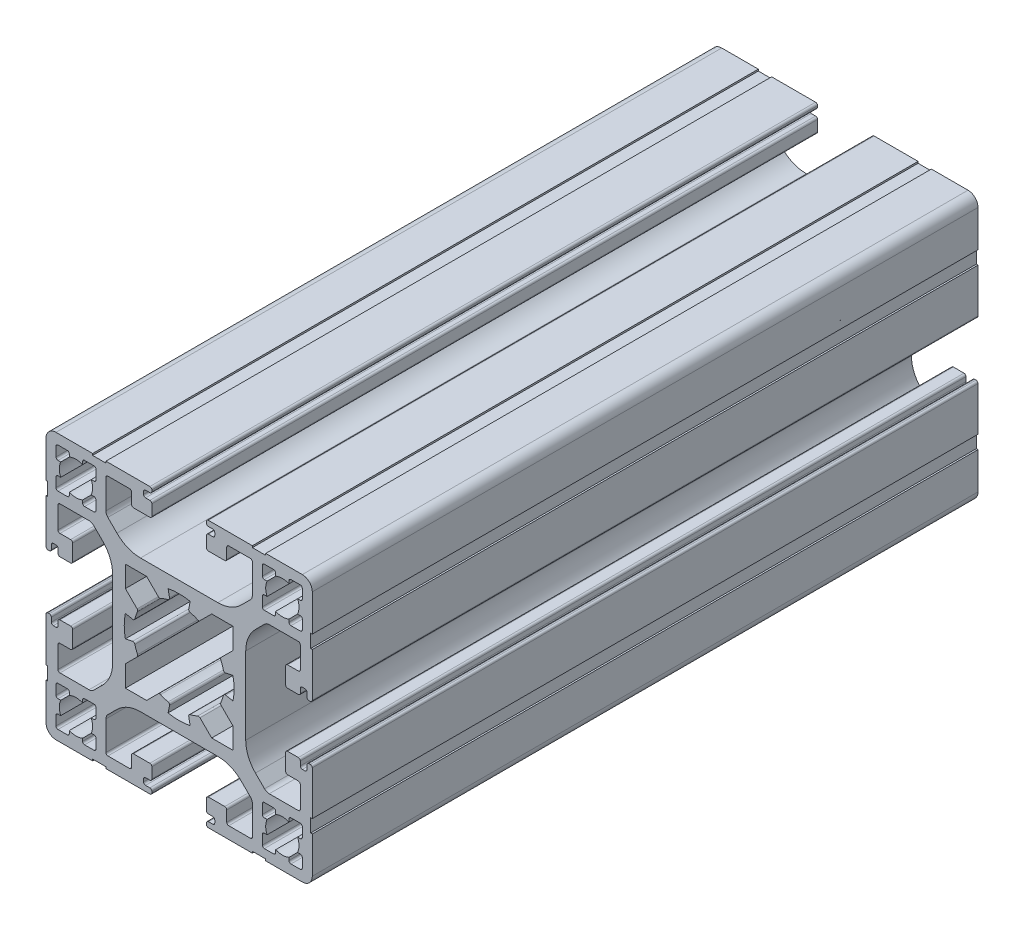
from build123d import *

# Parameters (mm, degrees)
QUADRADO_PF40_01_PERFIL_4040_B_SICO_1_DEPTH = 100


with BuildPart() as part:
    # Sketch1 → Quadrado PF40-01 - PERFIL 4040 BÁSICO(1) (new body)
    with BuildSketch(Plane(origin=(0, 0, 50), x_dir=(0, -1, 0), z_dir=(0, 0, -1))):
        with BuildLine():
            Line((-9.343145751, 11.464466094), (-10.707106781, 12.828427125))
            ThreePointArc((-10.707106781, 12.828427125), (-10.923879533, 13.152850474), (-11, 13.535533906))
            Line((-11, 13.535533906), (-11, 17.9))
            ThreePointArc((-11, 17.9), (-10.912132034, 18.112132034), (-10.7, 18.2))
            Line((-10.7, 18.2), (-7.45, 18.2))
            ThreePointArc((-7.45, 18.2), (-7.237867966, 18.112132034), (-7.15, 17.9))
            Line((-7.15, 17.9), (-7.15, 16.3))
            ThreePointArc((-7.15, 16.3), (-7.062132034, 16.087867966), (-6.85, 16))
            Line((-6.85, 16), (-4.4, 16))
            ThreePointArc((-4.4, 16), (-4.187867966, 16.087867966), (-4.1, 16.3))
            Line((-4.1, 16.3), (-4.1, 17.9))
            ThreePointArc((-4.1, 17.9), (-4.187867966, 18.112132034), (-4.4, 18.2))
            Line((-4.4, 18.2), (-5.05, 18.2))
            ThreePointArc((-5.05, 18.2), (-5.262132034, 18.287867966), (-5.35, 18.5))
            Line((-5.35, 18.5), (-5.35, 18.9))
            ThreePointArc((-5.35, 18.9), (-5.262132034, 19.112132034), (-5.05, 19.2))
            Line((-5.05, 19.2), (-4.4, 19.2))
            ThreePointArc((-4.4, 19.2), (-4.187867966, 19.287867966), (-4.1, 19.5))
            Line((-4.1, 19.5), (-4.1, 19.699999929))
            ThreePointArc((-4.1, 19.699999929), (-4.187867966, 19.912131964), (-4.4, 19.999999929))
            Line((-4.4, 19.999999929), (-10.999999929, 19.999999929))
            Line((-10.999999929, 19.999999929), (-10.999999929, 19.749999873))
            Line((-10.999999929, 19.749999873), (-12.999999929, 19.749999873))
            Line((-12.999999929, 19.749999873), (-12.999999929, 19.999999929))
            Line((-12.999999929, 19.999999929), (-18.499999873, 19.999999929))
            ThreePointArc((-18.499999873, 19.999999929), (-19.560660045, 19.560660101), (-19.999999873, 18.499999929))
            Line((-19.999999873, 18.499999929), (-19.999999873, 12.999999929))
            Line((-19.999999873, 12.999999929), (-19.749999873, 12.999999929))
            Line((-19.749999873, 12.999999929), (-19.749999873, 10.999999929))
            Line((-19.749999873, 10.999999929), (-19.999999929, 10.999999929))
            Line((-19.999999929, 10.999999929), (-19.999999929, 4.4))
            ThreePointArc((-19.999999929, 4.4), (-19.912131964, 4.187867966), (-19.699999929, 4.1))
            Line((-19.699999929, 4.1), (-19.5, 4.1))
            ThreePointArc((-19.5, 4.1), (-19.287867966, 4.187867966), (-19.2, 4.4))
            Line((-19.2, 4.4), (-19.2, 5.05))
            ThreePointArc((-19.2, 5.05), (-19.112132034, 5.262132034), (-18.9, 5.35))
            Line((-18.9, 5.35), (-18.5, 5.35))
            ThreePointArc((-18.5, 5.35), (-18.287867966, 5.262132034), (-18.2, 5.05))
            Line((-18.2, 5.05), (-18.2, 4.4))
            ThreePointArc((-18.2, 4.4), (-18.112132034, 4.187867966), (-17.9, 4.1))
            Line((-17.9, 4.1), (-16.3, 4.1))
            ThreePointArc((-16.3, 4.1), (-16.087867966, 4.187867966), (-16, 4.4))
            Line((-16, 4.4), (-16, 6.85))
            ThreePointArc((-16, 6.85), (-16.087867966, 7.062132034), (-16.3, 7.15))
            Line((-16.3, 7.15), (-17.9, 7.15))
            ThreePointArc((-17.9, 7.15), (-18.112132034, 7.237867966), (-18.2, 7.45))
            Line((-18.2, 7.45), (-18.2, 10.7))
            ThreePointArc((-18.2, 10.7), (-18.112132034, 10.912132034), (-17.9, 11))
            Line((-17.9, 11), (-13.535533906, 11))
            ThreePointArc((-13.535533906, 11), (-13.152850474, 10.923879533), (-12.828427125, 10.707106781))
            Line((-12.828427125, 10.707106781), (-11.464466094, 9.343145751))
            ThreePointArc((-11.464466094, 9.343145751), (-10.380602337, 7.721029006), (-10, 5.807611845))
            Line((-10, 5.807611845), (-10, -5.807611845))
            ThreePointArc((-10, -5.807611845), (-10.380602337, -7.721029006), (-11.464466094, -9.343145751))
            Line((-11.464466094, -9.343145751), (-12.828427125, -10.707106781))
            ThreePointArc((-12.828427125, -10.707106781), (-13.152850474, -10.923879533), (-13.535533906, -11))
            Line((-13.535533906, -11), (-17.9, -11))
            ThreePointArc((-17.9, -11), (-18.112132034, -10.912132034), (-18.2, -10.7))
            Line((-18.2, -10.7), (-18.2, -7.45))
            ThreePointArc((-18.2, -7.45), (-18.112132034, -7.237867966), (-17.9, -7.15))
            Line((-17.9, -7.15), (-16.3, -7.15))
            ThreePointArc((-16.3, -7.15), (-16.087867966, -7.062132034), (-16, -6.85))
            Line((-16, -6.85), (-16, -4.4))
            ThreePointArc((-16, -4.4), (-16.087867966, -4.187867966), (-16.3, -4.1))
            Line((-16.3, -4.1), (-17.9, -4.1))
            ThreePointArc((-17.9, -4.1), (-18.112132034, -4.187867966), (-18.2, -4.4))
            Line((-18.2, -4.4), (-18.2, -5.05))
            ThreePointArc((-18.2, -5.05), (-18.287867966, -5.262132034), (-18.5, -5.35))
            Line((-18.5, -5.35), (-18.9, -5.35))
            ThreePointArc((-18.9, -5.35), (-19.112132034, -5.262132034), (-19.2, -5.05))
            Line((-19.2, -5.05), (-19.2, -4.4))
            ThreePointArc((-19.2, -4.4), (-19.287867966, -4.187867966), (-19.5, -4.1))
            Line((-19.5, -4.1), (-19.699999929, -4.1))
            ThreePointArc((-19.699999929, -4.1), (-19.912131964, -4.187867966), (-19.999999929, -4.4))
            Line((-19.999999929, -4.4), (-19.999999929, -10.999999929))
            Line((-19.999999929, -10.999999929), (-19.749999873, -10.999999929))
            Line((-19.749999873, -10.999999929), (-19.749999873, -12.999999929))
            Line((-19.749999873, -12.999999929), (-19.999999873, -12.999999929))
            Line((-19.999999873, -12.999999929), (-19.999999873, -18.499999929))
            ThreePointArc((-19.999999873, -18.499999929), (-19.560660045, -19.560660101), (-18.499999873, -19.999999929))
            Line((-18.499999873, -19.999999929), (-12.999999929, -19.999999929))
            Line((-12.999999929, -19.999999929), (-12.999999929, -19.749999873))
            Line((-12.999999929, -19.749999873), (-10.999999929, -19.749999873))
            Line((-10.999999929, -19.749999873), (-10.999999929, -19.999999929))
            Line((-10.999999929, -19.999999929), (-4.4, -19.999999929))
            ThreePointArc((-4.4, -19.999999929), (-4.187867966, -19.912131964), (-4.1, -19.699999929))
            Line((-4.1, -19.699999929), (-4.1, -19.5))
            ThreePointArc((-4.1, -19.5), (-4.187867966, -19.287867966), (-4.4, -19.2))
            Line((-4.4, -19.2), (-5.05, -19.2))
            ThreePointArc((-5.05, -19.2), (-5.262132034, -19.112132034), (-5.35, -18.9))
            Line((-5.35, -18.9), (-5.35, -18.5))
            ThreePointArc((-5.35, -18.5), (-5.262132034, -18.287867966), (-5.05, -18.2))
            Line((-5.05, -18.2), (-4.4, -18.2))
            ThreePointArc((-4.4, -18.2), (-4.187867966, -18.112132034), (-4.1, -17.9))
            Line((-4.1, -17.9), (-4.1, -16.3))
            ThreePointArc((-4.1, -16.3), (-4.187867966, -16.087867966), (-4.4, -16))
            Line((-4.4, -16), (-6.85, -16))
            ThreePointArc((-6.85, -16), (-7.062132034, -16.087867966), (-7.15, -16.3))
            Line((-7.15, -16.3), (-7.15, -17.9))
            ThreePointArc((-7.15, -17.9), (-7.237867966, -18.112132034), (-7.45, -18.2))
            Line((-7.45, -18.2), (-10.7, -18.2))
            ThreePointArc((-10.7, -18.2), (-10.912132034, -18.112132034), (-11, -17.9))
            Line((-11, -17.9), (-11, -13.535533906))
            ThreePointArc((-11, -13.535533906), (-10.923879533, -13.152850474), (-10.707106781, -12.828427125))
            Line((-10.707106781, -12.828427125), (-9.343145751, -11.464466094))
            ThreePointArc((-9.343145751, -11.464466094), (-7.721029006, -10.380602337), (-5.807611845, -10))
            Line((-5.807611845, -10), (5.807611845, -10))
            ThreePointArc((5.807611845, -10), (7.721029006, -10.380602337), (9.343145751, -11.464466094))
            Line((9.343145751, -11.464466094), (10.707106781, -12.828427125))
            ThreePointArc((10.707106781, -12.828427125), (10.923879533, -13.152850474), (11, -13.535533906))
            Line((11, -13.535533906), (11, -17.9))
            ThreePointArc((11, -17.9), (10.912132034, -18.112132034), (10.7, -18.2))
            Line((10.7, -18.2), (7.45, -18.2))
            ThreePointArc((7.45, -18.2), (7.237867966, -18.112132034), (7.15, -17.9))
            Line((7.15, -17.9), (7.15, -16.3))
            ThreePointArc((7.15, -16.3), (7.062132034, -16.087867966), (6.85, -16))
            Line((6.85, -16), (4.4, -16))
            ThreePointArc((4.4, -16), (4.187867966, -16.087867966), (4.1, -16.3))
            Line((4.1, -16.3), (4.1, -17.9))
            ThreePointArc((4.1, -17.9), (4.187867966, -18.112132034), (4.4, -18.2))
            Line((4.4, -18.2), (5.05, -18.2))
            ThreePointArc((5.05, -18.2), (5.262132034, -18.287867966), (5.35, -18.5))
            Line((5.35, -18.5), (5.35, -18.9))
            ThreePointArc((5.35, -18.9), (5.262132034, -19.112132034), (5.05, -19.2))
            Line((5.05, -19.2), (4.4, -19.2))
            ThreePointArc((4.4, -19.2), (4.187867966, -19.287867966), (4.1, -19.5))
            Line((4.1, -19.5), (4.1, -19.699999929))
            ThreePointArc((4.1, -19.699999929), (4.187867966, -19.912131964), (4.4, -19.999999929))
            Line((4.4, -19.999999929), (10.999999929, -19.999999929))
            Line((10.999999929, -19.999999929), (10.999999929, -19.749999873))
            Line((10.999999929, -19.749999873), (12.999999929, -19.749999873))
            Line((12.999999929, -19.749999873), (12.999999929, -19.999999929))
            Line((12.999999929, -19.999999929), (18.499999873, -19.999999929))
            ThreePointArc((18.499999873, -19.999999929), (19.560660045, -19.560660101), (19.999999873, -18.499999929))
            Line((19.999999873, -18.499999929), (19.999999873, -12.999999929))
            Line((19.999999873, -12.999999929), (19.749999873, -12.999999929))
            Line((19.749999873, -12.999999929), (19.749999873, -10.999999929))
            Line((19.749999873, -10.999999929), (19.999999929, -10.999999929))
            Line((19.999999929, -10.999999929), (19.999999929, -4.4))
            ThreePointArc((19.999999929, -4.4), (19.912131964, -4.187867966), (19.699999929, -4.1))
            Line((19.699999929, -4.1), (19.5, -4.1))
            ThreePointArc((19.5, -4.1), (19.287867966, -4.187867966), (19.2, -4.4))
            Line((19.2, -4.4), (19.2, -5.05))
            ThreePointArc((19.2, -5.05), (19.112132034, -5.262132034), (18.9, -5.35))
            Line((18.9, -5.35), (18.5, -5.35))
            ThreePointArc((18.5, -5.35), (18.287867966, -5.262132034), (18.2, -5.05))
            Line((18.2, -5.05), (18.2, -4.4))
            ThreePointArc((18.2, -4.4), (18.112132034, -4.187867966), (17.9, -4.1))
            Line((17.9, -4.1), (16.3, -4.1))
            ThreePointArc((16.3, -4.1), (16.087867966, -4.187867966), (16, -4.4))
            Line((16, -4.4), (16, -6.85))
            ThreePointArc((16, -6.85), (16.087867966, -7.062132034), (16.3, -7.15))
            Line((16.3, -7.15), (17.9, -7.15))
            ThreePointArc((17.9, -7.15), (18.112132034, -7.237867966), (18.2, -7.45))
            Line((18.2, -7.45), (18.2, -10.7))
            ThreePointArc((18.2, -10.7), (18.112132034, -10.912132034), (17.9, -11))
            Line((17.9, -11), (13.535533906, -11))
            ThreePointArc((13.535533906, -11), (13.152850474, -10.923879533), (12.828427125, -10.707106781))
            Line((12.828427125, -10.707106781), (11.464466094, -9.343145751))
            ThreePointArc((11.464466094, -9.343145751), (10.380602337, -7.721029006), (10, -5.807611845))
            Line((10, -5.807611845), (10, 5.807611845))
            ThreePointArc((10, 5.807611845), (10.380602337, 7.721029006), (11.464466094, 9.343145751))
            Line((11.464466094, 9.343145751), (12.828427125, 10.707106781))
            ThreePointArc((12.828427125, 10.707106781), (13.152850474, 10.923879533), (13.535533906, 11))
            Line((13.535533906, 11), (17.9, 11))
            ThreePointArc((17.9, 11), (18.112132034, 10.912132034), (18.2, 10.7))
            Line((18.2, 10.7), (18.2, 7.45))
            ThreePointArc((18.2, 7.45), (18.112132034, 7.237867966), (17.9, 7.15))
            Line((17.9, 7.15), (16.3, 7.15))
            ThreePointArc((16.3, 7.15), (16.087867966, 7.062132034), (16, 6.85))
            Line((16, 6.85), (16, 4.4))
            ThreePointArc((16, 4.4), (16.087867966, 4.187867966), (16.3, 4.1))
            Line((16.3, 4.1), (17.9, 4.1))
            ThreePointArc((17.9, 4.1), (18.112132034, 4.187867966), (18.2, 4.4))
            Line((18.2, 4.4), (18.2, 5.05))
            ThreePointArc((18.2, 5.05), (18.287867966, 5.262132034), (18.5, 5.35))
            Line((18.5, 5.35), (18.9, 5.35))
            ThreePointArc((18.9, 5.35), (19.112132034, 5.262132034), (19.2, 5.05))
            Line((19.2, 5.05), (19.2, 4.4))
            ThreePointArc((19.2, 4.4), (19.287867966, 4.187867966), (19.5, 4.1))
            Line((19.5, 4.1), (19.699999929, 4.1))
            ThreePointArc((19.699999929, 4.1), (19.912131964, 4.187867966), (19.999999929, 4.4))
            Line((19.999999929, 4.4), (19.999999929, 10.999999929))
            Line((19.999999929, 10.999999929), (19.749999873, 10.999999929))
            Line((19.749999873, 10.999999929), (19.749999873, 12.999999929))
            Line((19.749999873, 12.999999929), (19.999999873, 12.999999929))
            Line((19.999999873, 12.999999929), (19.999999873, 18.499999929))
            ThreePointArc((19.999999873, 18.499999929), (19.560660045, 19.560660101), (18.499999873, 19.999999929))
            Line((18.499999873, 19.999999929), (12.999999929, 19.999999929))
            Line((12.999999929, 19.999999929), (12.999999929, 19.749999873))
            Line((12.999999929, 19.749999873), (10.999999929, 19.749999873))
            Line((10.999999929, 19.749999873), (10.999999929, 19.999999929))
            Line((10.999999929, 19.999999929), (4.4, 19.999999929))
            ThreePointArc((4.4, 19.999999929), (4.187867966, 19.912131964), (4.1, 19.699999929))
            Line((4.1, 19.699999929), (4.1, 19.5))
            ThreePointArc((4.1, 19.5), (4.187867966, 19.287867966), (4.4, 19.2))
            Line((4.4, 19.2), (5.05, 19.2))
            ThreePointArc((5.05, 19.2), (5.262132034, 19.112132034), (5.35, 18.9))
            Line((5.35, 18.9), (5.35, 18.5))
            ThreePointArc((5.35, 18.5), (5.262132034, 18.287867966), (5.05, 18.2))
            Line((5.05, 18.2), (4.4, 18.2))
            ThreePointArc((4.4, 18.2), (4.187867966, 18.112132034), (4.1, 17.9))
            Line((4.1, 17.9), (4.1, 16.3))
            ThreePointArc((4.1, 16.3), (4.187867966, 16.087867966), (4.4, 16))
            Line((4.4, 16), (6.85, 16))
            ThreePointArc((6.85, 16), (7.062132034, 16.087867966), (7.15, 16.3))
            Line((7.15, 16.3), (7.15, 17.9))
            ThreePointArc((7.15, 17.9), (7.237867966, 18.112132034), (7.45, 18.2))
            Line((7.45, 18.2), (10.7, 18.2))
            ThreePointArc((10.7, 18.2), (10.912132034, 18.112132034), (11, 17.9))
            Line((11, 17.9), (11, 13.535533906))
            ThreePointArc((11, 13.535533906), (10.923879533, 13.152850474), (10.707106781, 12.828427125))
            Line((10.707106781, 12.828427125), (9.343145751, 11.464466094))
            ThreePointArc((9.343145751, 11.464466094), (7.721029006, 10.380602337), (5.807611845, 10))
            Line((5.807611845, 10), (-5.807611845, 10))
            ThreePointArc((-5.807611845, 10), (-7.721029006, 10.380602337), (-9.343145751, 11.464466094))
        make_face()
        with BuildLine():
            Line((18.199999873, -16.499999929), (17.791287052, -16.499999929))
            ThreePointArc((17.791287052, -16.499999929), (17.999998571, -15.500001379), (17.791287052, -14.500002829))
            Line((17.791287052, -14.500002829), (18.199999873, -14.500002829))
            ThreePointArc((18.199999873, -14.500002829), (18.412131908, -14.412134864), (18.499999873, -14.200002829))
            Line((18.499999873, -14.200002829), (18.499999873, -12.800002829))
            ThreePointArc((18.499999873, -12.800002829), (18.412131908, -12.587870795), (18.199999873, -12.500002829))
            Line((18.199999873, -12.500002829), (16.799999873, -12.500002829))
            ThreePointArc((16.799999873, -12.500002829), (16.587867839, -12.587870795), (16.499999873, -12.800002829))
            Line((16.499999873, -12.800002829), (16.499999873, -13.2087141))
            ThreePointArc((16.499999873, -13.2087141), (15.499998571, -13.000001379), (14.49999727, -13.2087141))
            Line((14.49999727, -13.2087141), (14.49999727, -12.800002829))
            ThreePointArc((14.49999727, -12.800002829), (14.412129304, -12.587870795), (14.19999727, -12.500002829))
            Line((14.19999727, -12.500002829), (12.79999727, -12.500002829))
            ThreePointArc((12.79999727, -12.500002829), (12.587865235, -12.587870795), (12.49999727, -12.800002829))
            Line((12.49999727, -12.800002829), (12.49999727, -14.200002829))
            ThreePointArc((12.49999727, -14.200002829), (12.587865235, -14.412134864), (12.79999727, -14.500002829))
            Line((12.79999727, -14.500002829), (13.208710091, -14.500002829))
            ThreePointArc((13.208710091, -14.500002829), (12.999998571, -15.500001379), (13.208710091, -16.499999929))
            Line((13.208710091, -16.499999929), (12.79999727, -16.499999929))
            ThreePointArc((12.79999727, -16.499999929), (12.587865235, -16.587867895), (12.49999727, -16.799999929))
            Line((12.49999727, -16.799999929), (12.49999727, -18.199999929))
            ThreePointArc((12.49999727, -18.199999929), (12.587865235, -18.412131964), (12.79999727, -18.499999929))
            Line((12.79999727, -18.499999929), (14.19999727, -18.499999929))
            ThreePointArc((14.19999727, -18.499999929), (14.412129304, -18.412131964), (14.49999727, -18.199999929))
            Line((14.49999727, -18.199999929), (14.49999727, -17.791288659))
            ThreePointArc((14.49999727, -17.791288659), (15.499998571, -18.000001379), (16.499999873, -17.791288659))
            Line((16.499999873, -17.791288659), (16.499999873, -18.199999929))
            ThreePointArc((16.499999873, -18.199999929), (16.587867839, -18.412131964), (16.799999873, -18.499999929))
            Line((16.799999873, -18.499999929), (18.199999873, -18.499999929))
            ThreePointArc((18.199999873, -18.499999929), (18.412131908, -18.412131964), (18.499999873, -18.199999929))
            Line((18.499999873, -18.199999929), (18.499999873, -16.799999929))
            ThreePointArc((18.499999873, -16.799999929), (18.412131908, -16.587867895), (18.199999873, -16.499999929))
        make_face(mode=Mode.SUBTRACT)
        with BuildLine():
            Line((-6.997249465, 1.439096912), (-8.080865606, 1.661960003))
            ThreePointArc((-8.080865606, 1.661960003), (-8.25, 0), (-8.080865606, -1.661960003))
            Line((-8.080865606, -1.661960003), (-6.997249465, -1.439096912))
            ThreePointArc((-6.997249465, -1.439096912), (-6.777058504, -1.479021377), (-6.6457594, -1.660235526))
            ThreePointArc((-6.6457594, -1.660235526), (-6.474223632, -2.23761667), (-6.252630722, -2.797697099))
            ThreePointArc((-6.252630722, -2.797697099), (-6.231441739, -2.974622257), (-6.314336529, -3.132356014))
            Line((-6.314336529, -3.132356014), (-8.071067812, -4.889087297))
            Line((-8.071067812, -4.889087297), (-8.071067812, -8.071067812))
            Line((-8.071067812, -8.071067812), (-4.889087297, -8.071067812))
            Line((-4.889087297, -8.071067812), (-3.132356014, -6.314336529))
            ThreePointArc((-3.132356014, -6.314336529), (-2.974622257, -6.231441739), (-2.797697099, -6.252630722))
            ThreePointArc((-2.797697099, -6.252630722), (-2.23761667, -6.474223632), (-1.660235526, -6.6457594))
            ThreePointArc((-1.660235526, -6.6457594), (-1.479021377, -6.777058504), (-1.439096912, -6.997249465))
            Line((-1.439096912, -6.997249465), (-1.661960003, -8.080865606))
            ThreePointArc((-1.661960003, -8.080865606), (0, -8.25), (1.661960003, -8.080865606))
            Line((1.661960003, -8.080865606), (1.439096912, -6.997249465))
            ThreePointArc((1.439096912, -6.997249465), (1.479021377, -6.777058504), (1.660235526, -6.6457594))
            ThreePointArc((1.660235526, -6.6457594), (2.23761667, -6.474223632), (2.797697099, -6.252630722))
            ThreePointArc((2.797697099, -6.252630722), (2.974622257, -6.231441739), (3.132356014, -6.314336529))
            Line((3.132356014, -6.314336529), (4.889087297, -8.071067812))
            Line((4.889087297, -8.071067812), (8.071067812, -8.071067812))
            Line((8.071067812, -8.071067812), (8.071067812, -4.889087297))
            Line((8.071067812, -4.889087297), (6.314336529, -3.132356014))
            ThreePointArc((6.314336529, -3.132356014), (6.231441739, -2.974622257), (6.252630722, -2.797697099))
            ThreePointArc((6.252630722, -2.797697099), (6.474223632, -2.23761667), (6.6457594, -1.660235526))
            ThreePointArc((6.6457594, -1.660235526), (6.777058504, -1.479021377), (6.997249465, -1.439096912))
            Line((6.997249465, -1.439096912), (8.080865606, -1.661960003))
            ThreePointArc((8.080865606, -1.661960003), (8.25, 0), (8.080865606, 1.661960003))
            Line((8.080865606, 1.661960003), (6.997249465, 1.439096912))
            ThreePointArc((6.997249465, 1.439096912), (6.777058504, 1.479021377), (6.6457594, 1.660235526))
            ThreePointArc((6.6457594, 1.660235526), (6.474223632, 2.23761667), (6.252630722, 2.797697099))
            ThreePointArc((6.252630722, 2.797697099), (6.231441739, 2.974622257), (6.314336529, 3.132356014))
            Line((6.314336529, 3.132356014), (8.071067812, 4.889087297))
            Line((8.071067812, 4.889087297), (8.071067812, 8.071067812))
            Line((8.071067812, 8.071067812), (4.889087297, 8.071067812))
            Line((4.889087297, 8.071067812), (3.132356014, 6.314336529))
            ThreePointArc((3.132356014, 6.314336529), (2.974622257, 6.231441739), (2.797697099, 6.252630722))
            ThreePointArc((2.797697099, 6.252630722), (2.23761667, 6.474223632), (1.660235526, 6.6457594))
            ThreePointArc((1.660235526, 6.6457594), (1.479021377, 6.777058504), (1.439096912, 6.997249465))
            Line((1.439096912, 6.997249465), (1.661960003, 8.080865606))
            ThreePointArc((1.661960003, 8.080865606), (0, 8.25), (-1.661960003, 8.080865606))
            Line((-1.661960003, 8.080865606), (-1.439096912, 6.997249465))
            ThreePointArc((-1.439096912, 6.997249465), (-1.479021377, 6.777058504), (-1.660235526, 6.6457594))
            ThreePointArc((-1.660235526, 6.6457594), (-2.23761667, 6.474223632), (-2.797697099, 6.252630722))
            ThreePointArc((-2.797697099, 6.252630722), (-2.974622257, 6.231441739), (-3.132356014, 6.314336529))
            Line((-3.132356014, 6.314336529), (-4.889087297, 8.071067812))
            Line((-4.889087297, 8.071067812), (-8.071067812, 8.071067812))
            Line((-8.071067812, 8.071067812), (-8.071067812, 4.889087297))
            Line((-8.071067812, 4.889087297), (-6.314336529, 3.132356014))
            ThreePointArc((-6.314336529, 3.132356014), (-6.231441739, 2.974622257), (-6.252630722, 2.797697099))
            ThreePointArc((-6.252630722, 2.797697099), (-6.474223632, 2.23761667), (-6.6457594, 1.660235526))
            ThreePointArc((-6.6457594, 1.660235526), (-6.777058504, 1.479021377), (-6.997249465, 1.439096912))
        make_face(mode=Mode.SUBTRACT)
        with BuildLine():
            Line((-16.499999873, 17.791288659), (-16.499999873, 18.199999929))
            ThreePointArc((-16.499999873, 18.199999929), (-16.587867839, 18.412131964), (-16.799999873, 18.499999929))
            Line((-16.799999873, 18.499999929), (-18.199999873, 18.499999929))
            ThreePointArc((-18.199999873, 18.499999929), (-18.412131908, 18.412131964), (-18.499999873, 18.199999929))
            Line((-18.499999873, 18.199999929), (-18.499999873, 16.799999929))
            ThreePointArc((-18.499999873, 16.799999929), (-18.412131908, 16.587867895), (-18.199999873, 16.499999929))
            Line((-18.199999873, 16.499999929), (-17.791287052, 16.499999929))
            ThreePointArc((-17.791287052, 16.499999929), (-17.999998571, 15.500001379), (-17.791287052, 14.500002829))
            Line((-17.791287052, 14.500002829), (-18.199999873, 14.500002829))
            ThreePointArc((-18.199999873, 14.500002829), (-18.412131908, 14.412134864), (-18.499999873, 14.200002829))
            Line((-18.499999873, 14.200002829), (-18.499999873, 12.800002829))
            ThreePointArc((-18.499999873, 12.800002829), (-18.412131908, 12.587870795), (-18.199999873, 12.500002829))
            Line((-18.199999873, 12.500002829), (-16.799999873, 12.500002829))
            ThreePointArc((-16.799999873, 12.500002829), (-16.587867839, 12.587870795), (-16.499999873, 12.800002829))
            Line((-16.499999873, 12.800002829), (-16.499999873, 13.2087141))
            ThreePointArc((-16.499999873, 13.2087141), (-15.499998571, 13.000001379), (-14.49999727, 13.2087141))
            Line((-14.49999727, 13.2087141), (-14.49999727, 12.800002829))
            ThreePointArc((-14.49999727, 12.800002829), (-14.412129304, 12.587870795), (-14.19999727, 12.500002829))
            Line((-14.19999727, 12.500002829), (-12.79999727, 12.500002829))
            ThreePointArc((-12.79999727, 12.500002829), (-12.587865235, 12.587870795), (-12.49999727, 12.800002829))
            Line((-12.49999727, 12.800002829), (-12.49999727, 14.200002829))
            ThreePointArc((-12.49999727, 14.200002829), (-12.587865235, 14.412134864), (-12.79999727, 14.500002829))
            Line((-12.79999727, 14.500002829), (-13.208710091, 14.500002829))
            ThreePointArc((-13.208710091, 14.500002829), (-12.999998571, 15.500001379), (-13.208710091, 16.499999929))
            Line((-13.208710091, 16.499999929), (-12.79999727, 16.499999929))
            ThreePointArc((-12.79999727, 16.499999929), (-12.587865235, 16.587867895), (-12.49999727, 16.799999929))
            Line((-12.49999727, 16.799999929), (-12.49999727, 18.199999929))
            ThreePointArc((-12.49999727, 18.199999929), (-12.587865235, 18.412131964), (-12.79999727, 18.499999929))
            Line((-12.79999727, 18.499999929), (-14.19999727, 18.499999929))
            ThreePointArc((-14.19999727, 18.499999929), (-14.412129304, 18.412131964), (-14.49999727, 18.199999929))
            Line((-14.49999727, 18.199999929), (-14.49999727, 17.791288659))
            ThreePointArc((-14.49999727, 17.791288659), (-15.499998571, 18.000001379), (-16.499999873, 17.791288659))
        make_face(mode=Mode.SUBTRACT)
        with BuildLine():
            Line((14.49999727, 17.791288659), (14.49999727, 18.199999929))
            ThreePointArc((14.49999727, 18.199999929), (14.412129304, 18.412131964), (14.19999727, 18.499999929))
            Line((14.19999727, 18.499999929), (12.79999727, 18.499999929))
            ThreePointArc((12.79999727, 18.499999929), (12.587865235, 18.412131964), (12.49999727, 18.199999929))
            Line((12.49999727, 18.199999929), (12.49999727, 16.799999929))
            ThreePointArc((12.49999727, 16.799999929), (12.587865235, 16.587867895), (12.79999727, 16.499999929))
            Line((12.79999727, 16.499999929), (13.208710091, 16.499999929))
            ThreePointArc((13.208710091, 16.499999929), (12.999998571, 15.500001379), (13.208710091, 14.500002829))
            Line((13.208710091, 14.500002829), (12.79999727, 14.500002829))
            ThreePointArc((12.79999727, 14.500002829), (12.587865235, 14.412134864), (12.49999727, 14.200002829))
            Line((12.49999727, 14.200002829), (12.49999727, 12.800002829))
            ThreePointArc((12.49999727, 12.800002829), (12.587865235, 12.587870795), (12.79999727, 12.500002829))
            Line((12.79999727, 12.500002829), (14.19999727, 12.500002829))
            ThreePointArc((14.19999727, 12.500002829), (14.412129304, 12.587870795), (14.49999727, 12.800002829))
            Line((14.49999727, 12.800002829), (14.49999727, 13.2087141))
            ThreePointArc((14.49999727, 13.2087141), (15.499998571, 13.000001379), (16.499999873, 13.2087141))
            Line((16.499999873, 13.2087141), (16.499999873, 12.800002829))
            ThreePointArc((16.499999873, 12.800002829), (16.587867839, 12.587870795), (16.799999873, 12.500002829))
            Line((16.799999873, 12.500002829), (18.199999873, 12.500002829))
            ThreePointArc((18.199999873, 12.500002829), (18.412131908, 12.587870795), (18.499999873, 12.800002829))
            Line((18.499999873, 12.800002829), (18.499999873, 14.200002829))
            ThreePointArc((18.499999873, 14.200002829), (18.412131908, 14.412134864), (18.199999873, 14.500002829))
            Line((18.199999873, 14.500002829), (17.791287052, 14.500002829))
            ThreePointArc((17.791287052, 14.500002829), (17.999998571, 15.500001379), (17.791287052, 16.499999929))
            Line((17.791287052, 16.499999929), (18.199999873, 16.499999929))
            ThreePointArc((18.199999873, 16.499999929), (18.412131908, 16.587867895), (18.499999873, 16.799999929))
            Line((18.499999873, 16.799999929), (18.499999873, 18.199999929))
            ThreePointArc((18.499999873, 18.199999929), (18.412131908, 18.412131964), (18.199999873, 18.499999929))
            Line((18.199999873, 18.499999929), (16.799999873, 18.499999929))
            ThreePointArc((16.799999873, 18.499999929), (16.587867839, 18.412131964), (16.499999873, 18.199999929))
            Line((16.499999873, 18.199999929), (16.499999873, 17.791288659))
            ThreePointArc((16.499999873, 17.791288659), (15.499998571, 18.000001379), (14.49999727, 17.791288659))
        make_face(mode=Mode.SUBTRACT)
        with BuildLine():
            Line((-14.49999727, -17.791288659), (-14.49999727, -18.199999929))
            ThreePointArc((-14.49999727, -18.199999929), (-14.412129304, -18.412131964), (-14.19999727, -18.499999929))
            Line((-14.19999727, -18.499999929), (-12.79999727, -18.499999929))
            ThreePointArc((-12.79999727, -18.499999929), (-12.587865235, -18.412131964), (-12.49999727, -18.199999929))
            Line((-12.49999727, -18.199999929), (-12.49999727, -16.799999929))
            ThreePointArc((-12.49999727, -16.799999929), (-12.587865235, -16.587867895), (-12.79999727, -16.499999929))
            Line((-12.79999727, -16.499999929), (-13.208710091, -16.499999929))
            ThreePointArc((-13.208710091, -16.499999929), (-12.999998571, -15.500001379), (-13.208710091, -14.500002829))
            Line((-13.208710091, -14.500002829), (-12.79999727, -14.500002829))
            ThreePointArc((-12.79999727, -14.500002829), (-12.587865235, -14.412134864), (-12.49999727, -14.200002829))
            Line((-12.49999727, -14.200002829), (-12.49999727, -12.800002829))
            ThreePointArc((-12.49999727, -12.800002829), (-12.587865235, -12.587870795), (-12.79999727, -12.500002829))
            Line((-12.79999727, -12.500002829), (-14.19999727, -12.500002829))
            ThreePointArc((-14.19999727, -12.500002829), (-14.412129304, -12.587870795), (-14.49999727, -12.800002829))
            Line((-14.49999727, -12.800002829), (-14.49999727, -13.2087141))
            ThreePointArc((-14.49999727, -13.2087141), (-15.499998571, -13.000001379), (-16.499999873, -13.2087141))
            Line((-16.499999873, -13.2087141), (-16.499999873, -12.800002829))
            ThreePointArc((-16.499999873, -12.800002829), (-16.587867839, -12.587870795), (-16.799999873, -12.500002829))
            Line((-16.799999873, -12.500002829), (-18.199999873, -12.500002829))
            ThreePointArc((-18.199999873, -12.500002829), (-18.412131908, -12.587870795), (-18.499999873, -12.800002829))
            Line((-18.499999873, -12.800002829), (-18.499999873, -14.200002829))
            ThreePointArc((-18.499999873, -14.200002829), (-18.412131908, -14.412134864), (-18.199999873, -14.500002829))
            Line((-18.199999873, -14.500002829), (-17.791287052, -14.500002829))
            ThreePointArc((-17.791287052, -14.500002829), (-17.999998571, -15.500001379), (-17.791287052, -16.499999929))
            Line((-17.791287052, -16.499999929), (-18.199999873, -16.499999929))
            ThreePointArc((-18.199999873, -16.499999929), (-18.412131908, -16.587867895), (-18.499999873, -16.799999929))
            Line((-18.499999873, -16.799999929), (-18.499999873, -18.199999929))
            ThreePointArc((-18.499999873, -18.199999929), (-18.412131908, -18.412131964), (-18.199999873, -18.499999929))
            Line((-18.199999873, -18.499999929), (-16.799999873, -18.499999929))
            ThreePointArc((-16.799999873, -18.499999929), (-16.587867839, -18.412131964), (-16.499999873, -18.199999929))
            Line((-16.499999873, -18.199999929), (-16.499999873, -17.791288659))
            ThreePointArc((-16.499999873, -17.791288659), (-15.499998571, -18.000001379), (-14.49999727, -17.791288659))
        make_face(mode=Mode.SUBTRACT)
    extrude(amount=QUADRADO_PF40_01_PERFIL_4040_B_SICO_1_DEPTH)


solid = part.part
